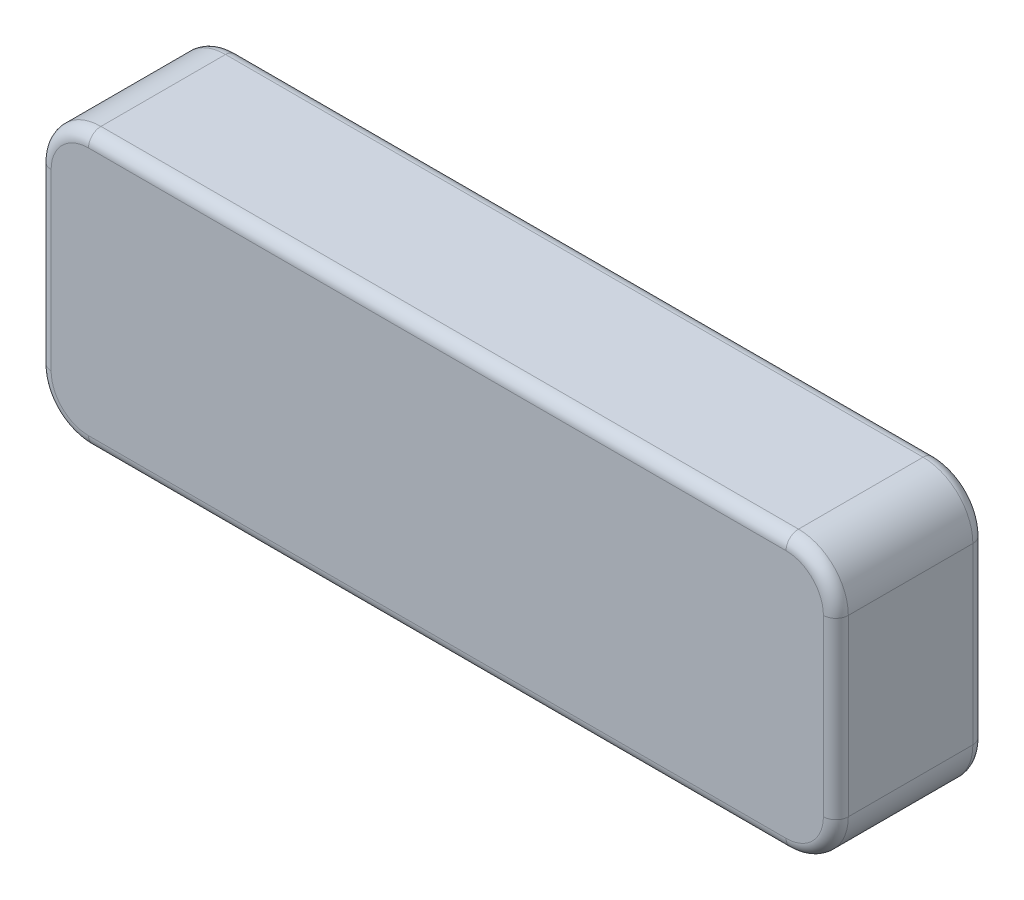
from build123d import *

# Parameters (mm, degrees)
SKETCH1_W           = 406.4
SKETCH1_H           = 139.7
BOSS_EXTRUDE1_DEPTH = 76.2
FILLET1_R           = 25.4
FILLET2_R           = 6.35


with BuildPart() as part:
    # Sketch1 → Boss-Extrude1 (new body)
    with BuildSketch(Plane.XY):
        Rectangle(SKETCH1_W, SKETCH1_H)
    extrude(amount=BOSS_EXTRUDE1_DEPTH)

    # Fillet1
    fillet1_edges = [part.edges().sort_by_distance(p)[0] for p in [
        (203.2, -69.85, 38.1),
        (-203.2, -69.85, 38.1),
        (-203.2, 69.85, 38.1),
        (203.2, 69.85, 38.1),
    ]]
    fillet(fillet1_edges, radius=FILLET1_R)

    # Fillet2
    fillet2_edges = [part.edges().sort_by_distance(p)[0] for p in [
        (203.2, 0, 0),
        (203.2, 0, 76.2),
        (0, -69.85, 0),
        (-203.2, 0, 0),
        (0, 69.85, 0),
        (195.760512242, 62.410512242, 0),
        (-195.760512242, 62.410512242, 0),
        (-195.760512242, -62.410512242, 0),
        (195.760512242, -62.410512242, 0),
        (0, -69.85, 76.2),
        (0, 69.85, 76.2),
        (-203.2, 0, 76.2),
        (195.760512242, 62.410512242, 76.2),
        (-195.760512242, 62.410512242, 76.2),
        (-195.760512242, -62.410512242, 76.2),
        (195.760512242, -62.410512242, 76.2),
    ]]
    fillet(fillet2_edges, radius=FILLET2_R)


solid = part.part
